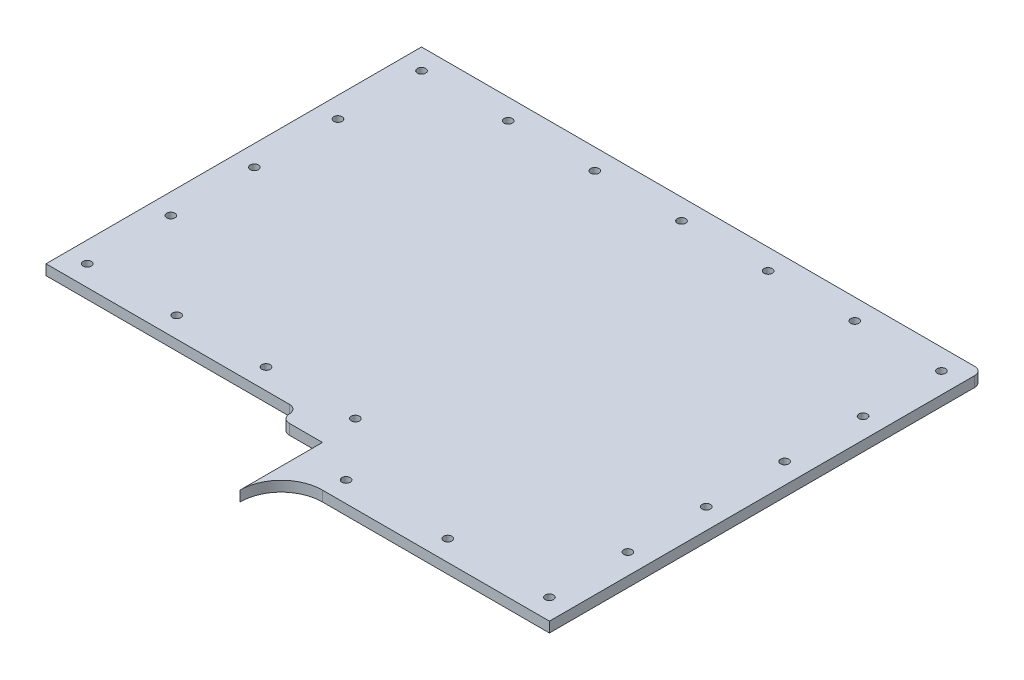
from build123d import *

# Parameters (mm, degrees)
BOSS_EXTRUDE1_DEPTH     = 1.5875
SKETCH2_R               = 0.635
CUT_EXTRUDE1_DEPTH      = 1
CUT_EXTRUDE1_DEPTH_BACK = 2.5875


with BuildPart() as part:
    # Sketch1 → Boss-Extrude1 (new body)
    with BuildSketch(Plane(origin=(0, 0, 0), x_dir=(1, 0, 0), z_dir=(0, 1, 0))):
        with BuildLine():
            Line((8.89, -66.675), (43.815, -66.675))
            Line((43.815, -66.675), (43.815, -1.27))
            ThreePointArc((43.815, -1.27), (43.453523156, -0.361476844), (42.545, 0))
            Line((42.545, 0), (-42.545, 0))
            Line((-42.545, 0), (-42.545, -57.785))
            Line((-42.545, -57.785), (-5.08, -57.785))
            ThreePointArc((-5.08, -57.785), (-4.181974388, -58.156974388), (-3.81, -59.055))
            ThreePointArc((-3.81, -59.055), (-3.438025612, -59.953025612), (-2.54, -60.325))
            Line((-2.54, -60.325), (2.54, -60.325))
            Line((2.54, -60.325), (2.54, -73.025))
            ThreePointArc((2.54, -73.025), (4.399871939, -68.534871939), (8.89, -66.675))
        make_face()
    extrude(amount=BOSS_EXTRUDE1_DEPTH)

    # Sketch2 → Cut-Extrude1 (cut, two sides)
    with BuildSketch(Plane(origin=(0, 1.5875, 0), x_dir=(-1, 0, 0), z_dir=(0, 1, 0))) as cut_extrude1_sk:
        with Locations((39.37, 3.175)):
            Circle(SKETCH2_R)
        with Locations((26.035, 3.175)):
            Circle(SKETCH2_R)
        with Locations((12.7, 3.175)):
            Circle(SKETCH2_R)
        with Locations((-0.635, 3.175)):
            Circle(SKETCH2_R)
        with Locations((-13.97, 3.175)):
            Circle(SKETCH2_R)
        with Locations((-27.305, 3.175)):
            Circle(SKETCH2_R)
        with Locations((-40.64, 3.175)):
            Circle(SKETCH2_R)
        with Locations((39.37, 16.03375)):
            Circle(SKETCH2_R)
        with Locations((39.37, 28.8925)):
            Circle(SKETCH2_R)
        with Locations((39.37, 41.75125)):
            Circle(SKETCH2_R)
        with Locations((-40.64, 15.24)):
            Circle(SKETCH2_R)
        with Locations((-40.64, 27.305)):
            Circle(SKETCH2_R)
        with Locations((-40.64, 39.37)):
            Circle(SKETCH2_R)
        with Locations((-40.64, 51.435)):
            Circle(SKETCH2_R)
        with Locations((-40.64, 63.5)):
            Circle(SKETCH2_R)
        with Locations((-24.994404736, 63.5)):
            Circle(SKETCH2_R)
        with Locations((-9.348809473, 63.5)):
            Circle(SKETCH2_R)
        with Locations((-1.889213751, 54.61)):
            Circle(SKETCH2_R)
        with Locations((11.863857499, 54.61)):
            Circle(SKETCH2_R)
        with Locations((25.61692875, 54.61)):
            Circle(SKETCH2_R)
        with Locations((39.37, 54.61)):
            Circle(SKETCH2_R)
    extrude(amount=CUT_EXTRUDE1_DEPTH, mode=Mode.SUBTRACT)
    extrude(cut_extrude1_sk.sketch, amount=-CUT_EXTRUDE1_DEPTH_BACK, mode=Mode.SUBTRACT)


solid = part.part
